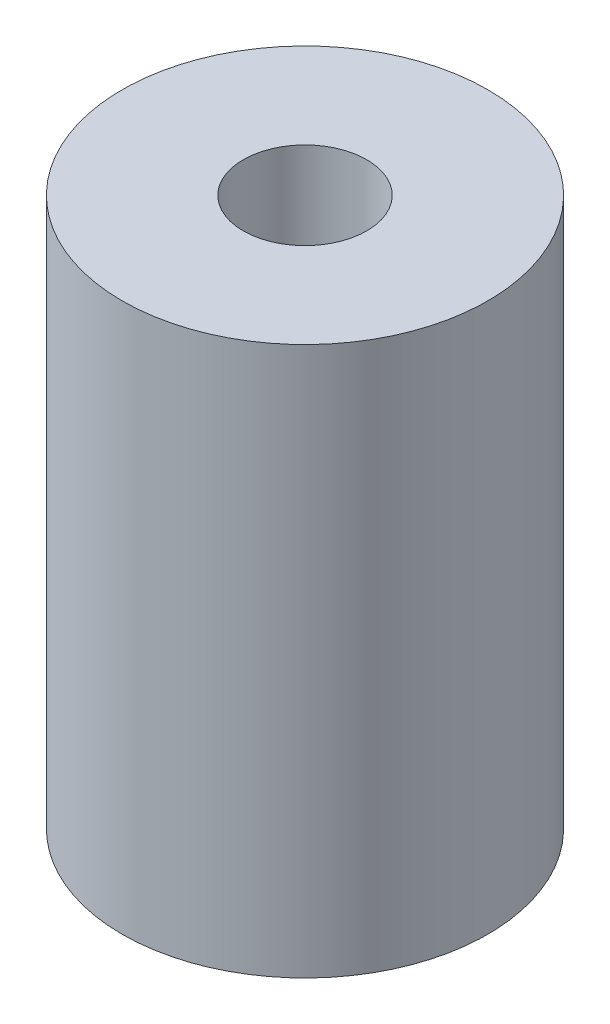
from build123d import *

# Parameters (mm, degrees)
SKETCH1_R           = 4
SKETCH1_R_2         = 1.35
BOSS_EXTRUDE1_DEPTH = 12


with BuildPart() as part:
    # Sketch1 → Boss-Extrude1 (new body)
    with BuildSketch(Plane(origin=(0, 0, 0), x_dir=(1, 0, 0), z_dir=(0, 1, 0))):
        Circle(SKETCH1_R)
        Circle(SKETCH1_R_2, mode=Mode.SUBTRACT)
    extrude(amount=BOSS_EXTRUDE1_DEPTH)


solid = part.part
